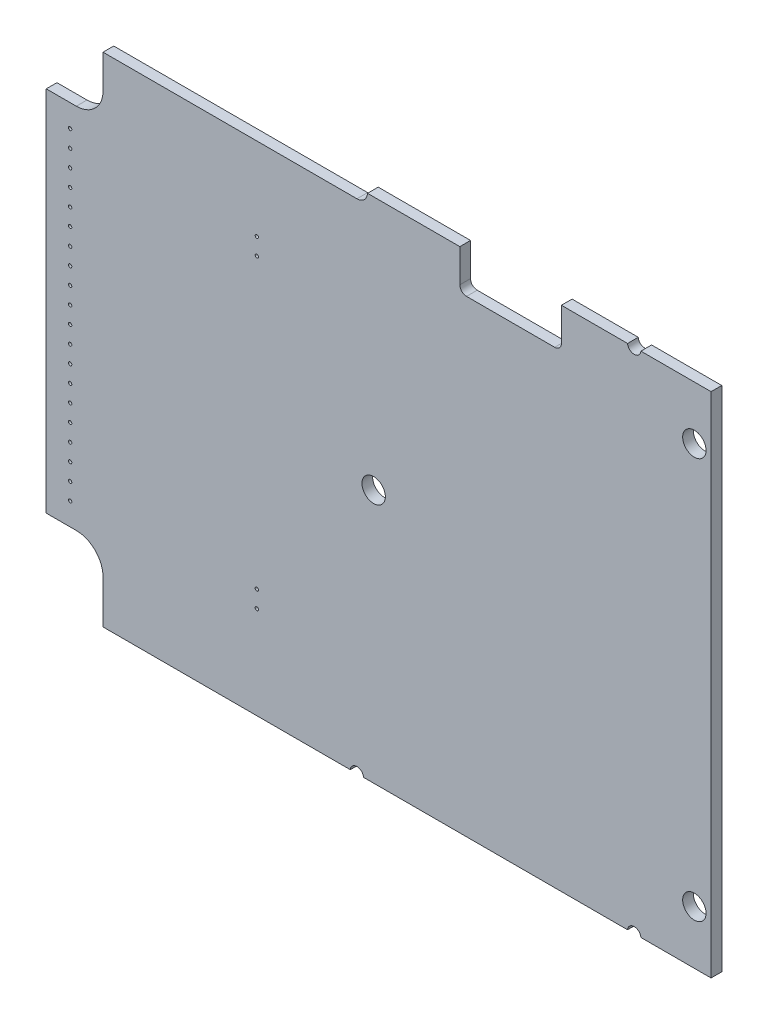
from build123d import *

# Parameters (mm, degrees)
BOSS_EXTRUDE1_DEPTH     = 1.6
SKETCH4_R               = 4
SKETCH4_R_2             = 1.75
CUT_EXTRUDE1_DEPTH      = 1
CUT_EXTRUDE1_DEPTH_BACK = 2.6
SKETCH5_W               = 50
SKETCH5_H               = 120
CUT_EXTRUDE2_DEPTH      = 2.6
SKETCH6_R               = 0.25
CUT_EXTRUDE3_DEPTH      = 2.6


with BuildPart() as part:
    # Sketch3 → Boss-Extrude1 (new body)
    with BuildSketch(Plane.XY):
        with BuildLine():
            Line((254.450402667, 57.180474091), (254.450402667, 62.180474091))
            Line((254.450402667, 62.180474091), (292.450402667, 62.180474091))
            ThreePointArc((292.450402667, 62.180474091), (293.540045449, 62.615149067), (294.031315558, 63.680474091))
            Line((294.031315558, 63.680474091), (307.850402667, 63.680474091))
            Line((307.850402667, 63.680474091), (307.850402667, 58.730474091))
            ThreePointArc((307.850402667, 58.730474091), (308.143295886, 58.02336731), (308.850402667, 57.730474091))
            Line((308.850402667, 57.730474091), (322.050402667, 57.730474091))
            ThreePointArc((322.050402667, 57.730474091), (322.757509449, 58.02336731), (323.050402667, 58.730474091))
            Line((323.050402667, 58.730474091), (323.050402667, 63.680474091))
            Line((323.050402667, 63.680474091), (332.953861053, 63.680474091))
            ThreePointArc((332.953861053, 63.680474091), (333.950402667, 62.76356928), (334.946944282, 63.680474091))
            Line((334.946944282, 63.680474091), (374.453861053, 63.680474091))
            ThreePointArc((374.453861053, 63.680474091), (375.450402667, 62.76356928), (376.446944282, 63.680474091))
            Line((376.446944282, 63.680474091), (390.950402667, 63.680474091))
            ThreePointArc((390.950402667, 63.680474091), (393.071723011, 62.801794434), (393.950402667, 60.680474091))
            Line((393.950402667, 60.680474091), (393.950402667, 58.177015705))
            ThreePointArc((393.950402667, 58.177015705), (393.033497857, 57.180474091), (393.950402667, 56.183932476))
            Line((393.950402667, 56.183932476), (393.950402667, -4.822984295))
            ThreePointArc((393.950402667, -4.822984295), (393.033497857, -5.819525909), (393.950402667, -6.816067524))
            Line((393.950402667, -6.816067524), (393.950402667, -9.319525909))
            ThreePointArc((393.950402667, -9.319525909), (393.071723011, -11.440846253), (390.950402667, -12.319525909))
            Line((390.950402667, -12.319525909), (376.446944282, -12.319525909))
            ThreePointArc((376.446944282, -12.319525909), (375.450402667, -11.402621099), (374.453861053, -12.319525909))
            Line((374.453861053, -12.319525909), (334.946944282, -12.319525909))
            ThreePointArc((334.946944282, -12.319525909), (333.950402667, -11.402621099), (332.953861053, -12.319525909))
            Line((332.953861053, -12.319525909), (293.446944282, -12.319525909))
            ThreePointArc((293.446944282, -12.319525909), (292.450402667, -11.402621099), (291.453861053, -12.319525909))
            Line((291.453861053, -12.319525909), (254.450402667, -12.319525909))
            Line((254.450402667, -12.319525909), (254.450402667, -5.819525909))
            ThreePointArc((254.450402667, -5.819525909), (253.278829792, -2.991098784), (250.450402667, -1.819525909))
            Line((250.450402667, -1.819525909), (245.950402667, -1.819525909))
            Line((245.950402667, -1.819525909), (245.950402667, 53.180474091))
            Line((245.950402667, 53.180474091), (250.450402667, 53.180474091))
            ThreePointArc((250.450402667, 53.180474091), (253.278829792, 54.352046966), (254.450402667, 57.180474091))
        make_face()
    extrude(amount=BOSS_EXTRUDE1_DEPTH)

    # Sketch4 → Cut-Extrude1 (cut, two sides)
    with BuildSketch(Plane.XY.offset(1.6)) as cut_extrude1_sk:
        with Locations((375.450402667, -5.819525909)):
            Circle(SKETCH4_R)
        with Locations((342.950402667, -4.319525909)):
            Circle(SKETCH4_R_2)
        with Locations((294.950402667, 25.680474091)):
            Circle(SKETCH4_R_2)
        with Locations((342.950402667, 55.680474091)):
            Circle(SKETCH4_R_2)
        with Locations((375.450402667, 57.180474091)):
            Circle(SKETCH4_R)
    extrude(amount=CUT_EXTRUDE1_DEPTH, mode=Mode.SUBTRACT)
    extrude(cut_extrude1_sk.sketch, amount=-CUT_EXTRUDE1_DEPTH_BACK, mode=Mode.SUBTRACT)

    # Sketch5 → Cut-Extrude2 (cut, through all)
    with BuildSketch(Plane.XY.offset(1.6)):
        with Locations((370.450402667, 25.680474091)):
            Rectangle(SKETCH5_W, SKETCH5_H)
    extrude(amount=-CUT_EXTRUDE2_DEPTH, mode=Mode.SUBTRACT)

    # Sketch6 → Cut-Extrude3 (cut, through all)
    with BuildSketch(Plane.XY.offset(1.6)):
        with Locations((249.525402667, 49.810474091)):
            Circle(SKETCH6_R)
        with Locations((277.465402667, 49.810474091)):
            Circle(SKETCH6_R)
        with Locations((277.465402667, 47.270474091)):
            Circle(SKETCH6_R)
        with Locations((277.465402667, 4.090474091)):
            Circle(SKETCH6_R)
        with Locations((277.465402667, 1.550474091)):
            Circle(SKETCH6_R)
        with Locations((249.525402667, 1.550474091)):
            Circle(SKETCH6_R)
        with Locations((249.525402667, 4.090474091)):
            Circle(SKETCH6_R)
        with Locations((249.525402667, 6.630474091)):
            Circle(SKETCH6_R)
        with Locations((249.525402667, 9.170474091)):
            Circle(SKETCH6_R)
        with Locations((249.525402667, 11.710474091)):
            Circle(SKETCH6_R)
        with Locations((249.525402667, 14.250474091)):
            Circle(SKETCH6_R)
        with Locations((249.525402667, 16.790474091)):
            Circle(SKETCH6_R)
        with Locations((249.525402667, 19.330474091)):
            Circle(SKETCH6_R)
        with Locations((249.525402667, 21.870474091)):
            Circle(SKETCH6_R)
        with Locations((249.525402667, 24.410474091)):
            Circle(SKETCH6_R)
        with Locations((249.525402667, 26.950474091)):
            Circle(SKETCH6_R)
        with Locations((249.525402667, 29.490474091)):
            Circle(SKETCH6_R)
        with Locations((249.525402667, 32.030474091)):
            Circle(SKETCH6_R)
        with Locations((249.525402667, 34.570474091)):
            Circle(SKETCH6_R)
        with Locations((249.525402667, 37.110474091)):
            Circle(SKETCH6_R)
        with Locations((249.525402667, 39.650474091)):
            Circle(SKETCH6_R)
        with Locations((249.525402667, 42.190474091)):
            Circle(SKETCH6_R)
        with Locations((249.525402667, 44.730474091)):
            Circle(SKETCH6_R)
        with Locations((249.525402667, 47.270474091)):
            Circle(SKETCH6_R)
    extrude(amount=-CUT_EXTRUDE3_DEPTH, mode=Mode.SUBTRACT)


solid = part.part
